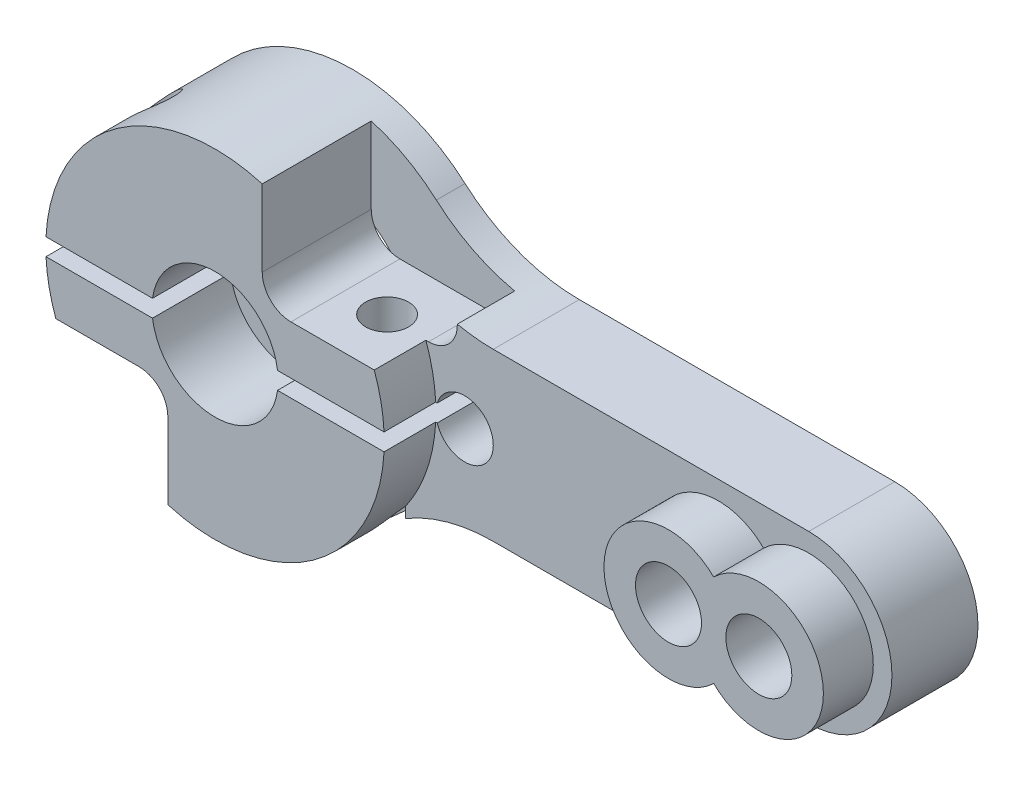
from build123d import *

# Parameters (mm, degrees)
SKETCH1_R           = 1.4605
SKETCH1_R_2         = 1.524
SKETCH1_R_3         = 1.27
BOSS_EXTRUDE2_DEPTH = 3.81
SKETCH2_R           = 1.4605
BOSS_EXTRUDE3_DEPTH = 2.2098
SKETCH3_R           = 7.493
SKETCH3_R_2         = 2.794
BOSS_EXTRUDE4_DEPTH = 2.286
SKETCH4_R           = 2.794
CUT_EXTRUDE1_DEPTH  = 3.4544
CUT_EXTRUDE2_DEPTH  = 4.826
SKETCH6_R           = 0.9525
CUT_EXTRUDE3_DEPTH  = 11.033
SKETCH7_R           = 0.9525
CUT_EXTRUDE4_DEPTH  = 11.0330001
SKETCH8_W           = 15.900663219
SKETCH8_H           = 0.762
CUT_EXTRUDE5_DEPTH  = 7.0960001
SKETCH9_R           = 3.937
CUT_EXTRUDE6_DEPTH  = 1.27


with BuildPart() as part:
    # Sketch1 → Boss-Extrude2 (new body)
    with BuildSketch(Plane.XY):
        with BuildLine():
            Line((24, 3.683), (10.03219617, 3.683))
            ThreePointArc((10.03219617, 3.683), (7.326823365, 4.179422389), (4.973946, 5.604008403))
            ThreePointArc((4.973946, 5.604008403), (-7.493, 0), (4.973946, -5.604008403))
            ThreePointArc((4.973946, -5.604008403), (7.326823365, -4.179422389), (10.03219617, -3.683))
            Line((10.03219617, -3.683), (24, -3.683))
            ThreePointArc((24, -3.683), (27.683, 0), (24, 3.683))
        make_face()
        with Locations((24, 0)):
            Circle(SKETCH1_R, mode=Mode.SUBTRACT)
        with Locations((20, 0)):
            Circle(SKETCH1_R, mode=Mode.SUBTRACT)
        Circle(SKETCH1_R_2, mode=Mode.SUBTRACT)
        with Locations((8.763, 0)):
            Circle(SKETCH1_R_3, mode=Mode.SUBTRACT)
    extrude(amount=BOSS_EXTRUDE2_DEPTH)

    # Sketch2 → Boss-Extrude3 (add)
    with BuildSketch(Plane.XY.offset(3.81)):
        with BuildLine():
            ThreePointArc((22, -2.040908192), (26.8575, 0), (22, 2.040908192))
            ThreePointArc((22, 2.040908192), (17.1425, 0), (22, -2.040908192))
        make_face()
        with Locations((20, 0)):
            Circle(SKETCH2_R, mode=Mode.SUBTRACT)
        with Locations((24, 0)):
            Circle(SKETCH2_R, mode=Mode.SUBTRACT)
    extrude(amount=BOSS_EXTRUDE3_DEPTH)

    # Sketch3 → Boss-Extrude4 (add)
    with BuildSketch(Plane.XY.offset(3.81)):
        Circle(SKETCH3_R)
        Circle(SKETCH3_R_2, mode=Mode.SUBTRACT)
    extrude(amount=BOSS_EXTRUDE4_DEPTH)

    # Sketch4 → Cut-Extrude1 (cut)
    with BuildSketch(Plane.XY.offset(6.096)):
        Circle(SKETCH4_R)
    extrude(amount=-CUT_EXTRUDE1_DEPTH, mode=Mode.SUBTRACT)

    # Sketch5 → Cut-Extrude2 (cut)
    with BuildSketch(Plane.XY.offset(6.096)):
        with BuildLine():
            Line((-2.090104165, -8.640089248), (-2.090104165, -3.81))
            ThreePointArc((-2.090104165, -3.81), (-2.462078553, -2.911974388), (-3.360104165, -2.54))
            Line((-3.360104165, -2.54), (-7.170104165, -2.54))
            ThreePointArc((-7.170104165, -2.54), (-8.068129777, -2.911974388), (-8.440104165, -3.81))
            Line((-8.440104165, -3.81), (-8.440104165, -8.640089248))
            Line((-8.440104165, -8.640089248), (-2.090104165, -8.640089248))
        make_face()
        with BuildLine():
            Line((8.440104165, 8.640089248), (2.090104165, 8.640089248))
            Line((2.090104165, 8.640089248), (2.090104165, 3.81))
            ThreePointArc((2.090104165, 3.81), (2.462078553, 2.911974388), (3.360104165, 2.54))
            Line((3.360104165, 2.54), (7.170104165, 2.54))
            ThreePointArc((7.170104165, 2.54), (8.068129777, 2.911974388), (8.440104165, 3.81))
            Line((8.440104165, 3.81), (8.440104165, 8.640089248))
        make_face()
    extrude(amount=-CUT_EXTRUDE2_DEPTH, mode=Mode.SUBTRACT)

    # Sketch6 → Cut-Extrude3 (cut, through all)
    with BuildSketch(Plane(origin=(0, -2.54, 0), x_dir=(-1, 0, 0), z_dir=(0, -1, 0))):
        with Locations((5.20473111, -3.683)):
            Circle(SKETCH6_R)
    extrude(amount=-CUT_EXTRUDE3_DEPTH, mode=Mode.SUBTRACT)

    # Sketch7 → Cut-Extrude4 (cut, through all)
    with BuildSketch(Plane(origin=(0, 2.54, 0), x_dir=(1, 0, 0), z_dir=(0, 1, 0))):
        with Locations((5.20473111, -3.683)):
            Circle(SKETCH7_R)
    extrude(amount=-CUT_EXTRUDE4_DEPTH, mode=Mode.SUBTRACT)

    # Sketch8 → Cut-Extrude5 (cut, through all)
    with BuildSketch(Plane.XY.offset(6.096)):
        with Locations((0.457331609, 0)):
            Rectangle(SKETCH8_W, SKETCH8_H)
    extrude(amount=-CUT_EXTRUDE5_DEPTH, mode=Mode.SUBTRACT)

    # Sketch9 → Cut-Extrude6 (cut)
    with BuildSketch(Plane(origin=(0, 0, 0), x_dir=(-1, 0, 0), z_dir=(0, 0, -1))):
        Circle(SKETCH9_R)
    extrude(amount=-CUT_EXTRUDE6_DEPTH, mode=Mode.SUBTRACT)


solid = part.part
